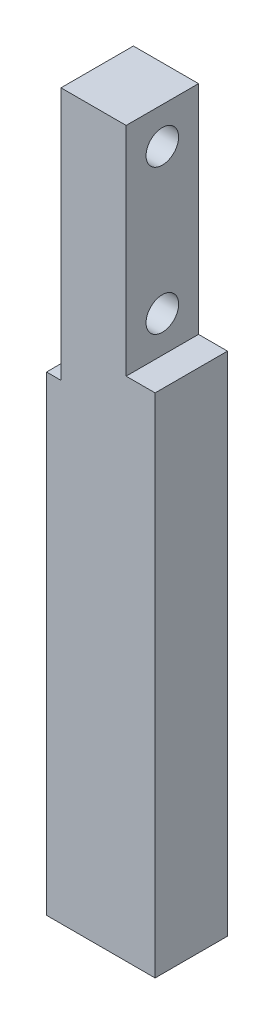
from build123d import *

# Parameters (mm, degrees)
BOSS_EXTRUDE1_DEPTH       = 10
SKETCH2_R                 = 4
CUT_EXTRUDE1_DEPTH        = 4.5
SKETCH3_R                 = 2.25
CUT_EXTRUDE2_DEPTH        = 9.5
M4X0_7_TAPPED_HOLE1_D     = 3.3
M4X0_7_TAPPED_HOLE1_DEPTH = 8
M4X0_7_TAPPED_HOLE1_TIP   = 0.991420021


with BuildPart() as part:
    # Sketch1 → Boss-Extrude1 (new body)
    with BuildSketch(Plane.XY):
        Polygon((-7.612, 62.794), (1.388, 62.794), (1.388, 32.794), (5.388, 32.794), (5.388, -37.206), (-9.612, -37.206), (-9.612, 27.794), (-7.612, 27.794), align=None)
    extrude(amount=BOSS_EXTRUDE1_DEPTH)

    # Sketch2 → Cut-Extrude1 (cut)
    with BuildSketch(Plane.ZY.offset(7.612)):
        with Locations((5, 57.794)):
            Circle(SKETCH2_R)
        with Locations((5, 37.794)):
            Circle(SKETCH2_R)
    extrude(amount=-CUT_EXTRUDE1_DEPTH, mode=Mode.SUBTRACT)

    # Sketch3 → Cut-Extrude2 (cut, through all)
    with BuildSketch(Plane.ZY.offset(3.112)):
        with Locations((5, 37.794)):
            Circle(SKETCH3_R)
        with Locations((5, 57.794)):
            Circle(SKETCH3_R)
    extrude(amount=-CUT_EXTRUDE2_DEPTH, mode=Mode.SUBTRACT)

    # M4x0.7 Tapped Hole1
    with Locations(Plane.ZY.offset(9.612)):
        with Locations((5, 2.794), (5, -27.206)):
            Hole(M4X0_7_TAPPED_HOLE1_D / 2, depth=M4X0_7_TAPPED_HOLE1_DEPTH)
            with Locations((0, 0, -(M4X0_7_TAPPED_HOLE1_DEPTH + M4X0_7_TAPPED_HOLE1_TIP / 2))):  # 118° drill point
                Cone(0, M4X0_7_TAPPED_HOLE1_D / 2, M4X0_7_TAPPED_HOLE1_TIP, mode=Mode.SUBTRACT)


solid = part.part
